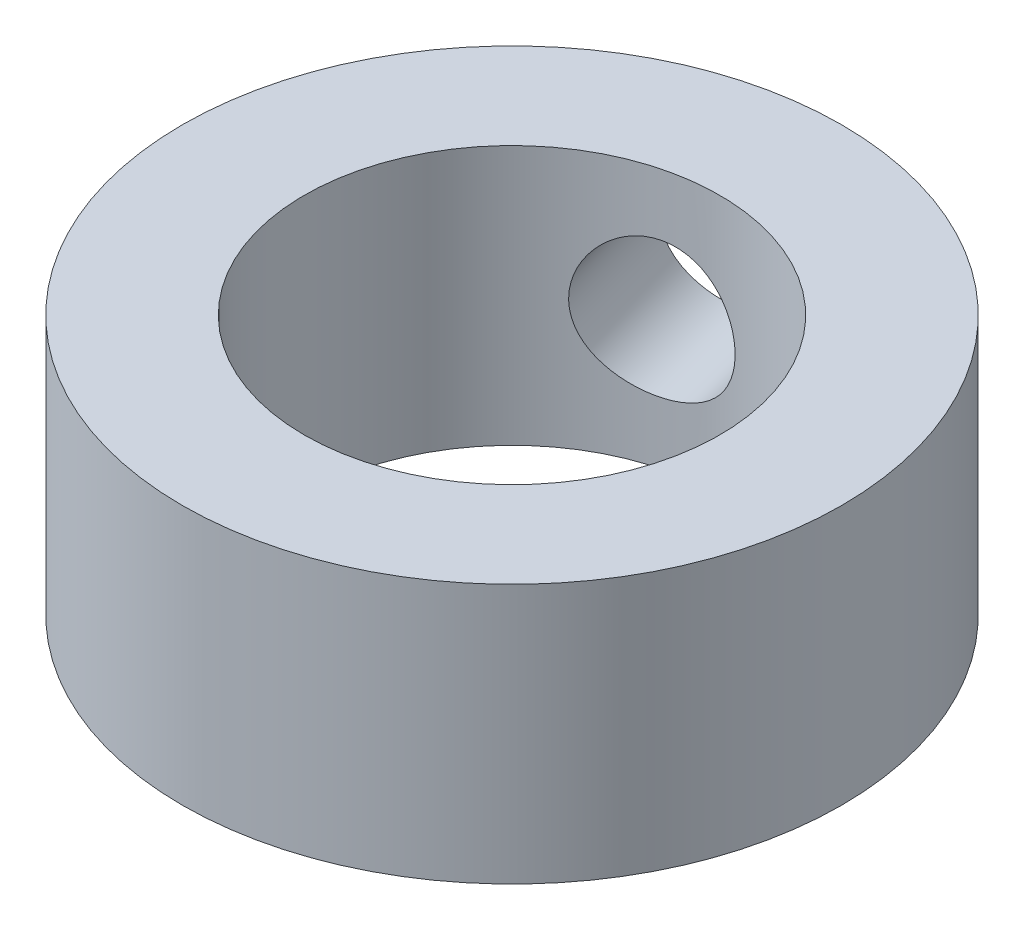
from build123d import *

# Parameters (mm, degrees)
SKETCH1_R                        = 25.4
BOSS_EXTRUDE1_DEPTH              = 20
SKETCH2_R                        = 16
CUT_EXTRUDE1_DEPTH               = 21
F_10_5_10_5_DIAMETER_HOLE1_D     = 10.5
F_10_5_10_5_DIAMETER_HOLE1_DEPTH = 30
F_10_5_10_5_DIAMETER_HOLE1_TIP   = 3.15451825


with BuildPart() as part:
    # Sketch1 → Boss-Extrude1 (new body)
    with BuildSketch(Plane(origin=(0, 0, 0), x_dir=(1, 0, 0), z_dir=(0, 1, 0))):
        Circle(SKETCH1_R)
    extrude(amount=BOSS_EXTRUDE1_DEPTH)

    # Sketch2 → Cut-Extrude1 (cut, through all)
    with BuildSketch(Plane(origin=(0, 20, 0), x_dir=(1, 0, 0), z_dir=(0, 1, 0))):
        Circle(SKETCH2_R)
    extrude(amount=-CUT_EXTRUDE1_DEPTH, mode=Mode.SUBTRACT)

    # Ø10.5 (10.5) Diameter Hole1
    with Locations(Plane(origin=(-6.456859903, 10, -24.565605228), x_dir=(-0.967149812, 0, 0.254207083), z_dir=(-0.254207083, 0, -0.967149812))):
        with Locations((0, 0)):
            Hole(F_10_5_10_5_DIAMETER_HOLE1_D / 2, depth=F_10_5_10_5_DIAMETER_HOLE1_DEPTH)
            with Locations((0, 0, -(F_10_5_10_5_DIAMETER_HOLE1_DEPTH + F_10_5_10_5_DIAMETER_HOLE1_TIP / 2))):  # 118° drill point
                Cone(0, F_10_5_10_5_DIAMETER_HOLE1_D / 2, F_10_5_10_5_DIAMETER_HOLE1_TIP, mode=Mode.SUBTRACT)


solid = part.part
